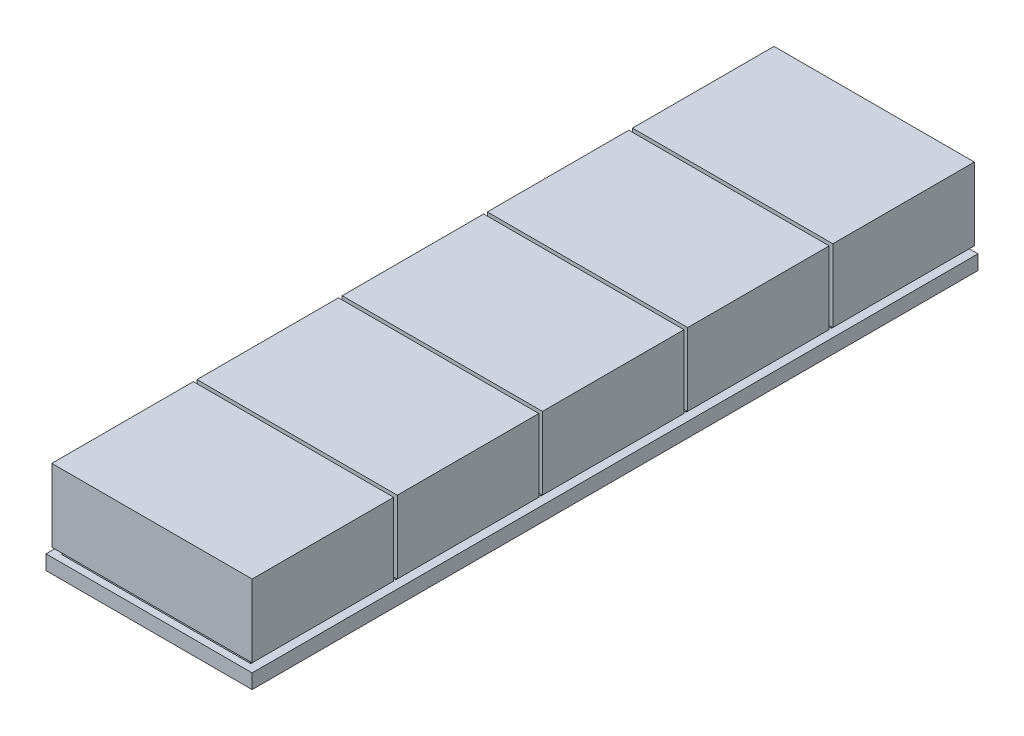
from build123d import *

# Parameters (mm, degrees)
SKETCH1_W           = 71
SKETCH1_H           = 250
BOSS_EXTRUDE1_DEPTH = 5
SKETCH2_W           = 65
SKETCH2_H           = 45
BOSS_EXTRUDE3_DEPTH = 2
LPATTERN1_COUNT     = 5
LPATTERN1_PITCH     = 50
SKETCH3_W           = 69
SKETCH3_H           = 48.754858224
BOSS_EXTRUDE8_DEPTH = 25
LPATTERN5_COUNT     = 5
LPATTERN5_PITCH     = 50


with BuildPart() as part:
    # Sketch1 → Boss-Extrude1 (new body)
    with BuildSketch(Plane(origin=(0, 0, 0), x_dir=(1, 0, 0), z_dir=(0, 1, 0))):
        Rectangle(SKETCH1_W, SKETCH1_H)
    extrude(amount=BOSS_EXTRUDE1_DEPTH)

    # Sketch2 → Boss-Extrude3 (add)
    with BuildSketch(Plane(origin=(0, 5, 0), x_dir=(1, 0, 0), z_dir=(0, 1, 0))):
        with Locations((0, -100)):
            Rectangle(SKETCH2_W, SKETCH2_H)
    boss_extrude3 = extrude(amount=BOSS_EXTRUDE3_DEPTH)

    # LPattern1: Boss-Extrude3 ×5
    with Locations(*[(0, 0, -i * LPATTERN1_PITCH) for i in range(1, LPATTERN1_COUNT)]):
        add(boss_extrude3)

    # Sketch3 → Boss-Extrude8 (add)
    with BuildSketch(Plane(origin=(0, 7, 0), x_dir=(1, 0, 0), z_dir=(0, 1, 0))):
        with Locations((0, -99.635002086)):
            Rectangle(SKETCH3_W, SKETCH3_H)
    boss_extrude8 = extrude(amount=BOSS_EXTRUDE8_DEPTH)

    # LPattern5: Boss-Extrude8 ×5
    with Locations(*[(0, 0, -i * LPATTERN5_PITCH) for i in range(1, LPATTERN5_COUNT)]):
        add(boss_extrude8)


solid = part.part
